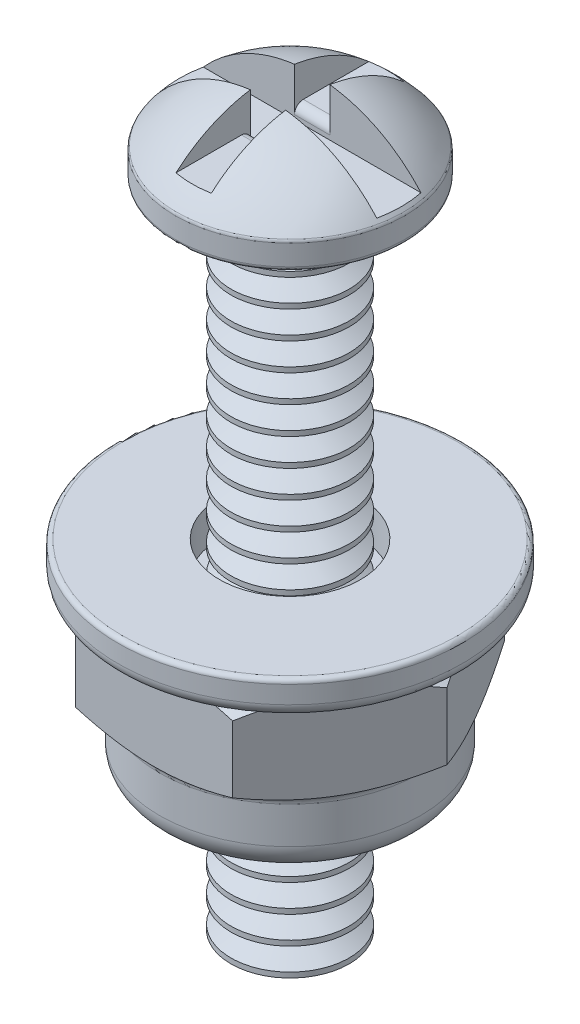
from build123d import *

# Parameters (mm, degrees)
SKETCH2_W                          = 1.27
SKETCH2_H                          = 1.778
LONG_CUT_PHILLIPS_DEPTH            = 4.3020001
LONG_CUT_PHILLIPS_DEPTH_BACK       = 4.3020001
SKETCH3_W                          = 1.016
SKETCH3_H                          = 1.27
SHORT_CUT_PHILLIPS_DEPTH           = 4.3020001
SHORT_CUT_PHILLIPS_DEPTH_BACK      = 4.3020001
PHILLIPS_FILLET_R                  = 0.254
LPATTERN_THREADS_COUNT             = 24
LPATTERN_THREADS_PITCH             = 0.79375
SKETCH5_R                          = 1.35255
NUT_TAP_HOLE_36_DRILL_0_1065_DEPTH = 2.794
SKETCH8_R                          = 3.7592
SKETCH8_R_2                        = 1.35255
LOCK_NUT_EXTRUDE_DEPTH             = 1.9685
SKETCH9_R                          = 1.778
LOCK_NUT_CUT_DEPTH                 = 0.508
LOCK_NUT_FILLET_1_R                = 0.762
LOCK_NUT_FILLET_2_R                = 0.254
SKETCH7_R                          = 4.953
SKETCH7_R_2                        = 2.032
WASHER_DEPTH                       = 1.016
WASHER_FILLET_1_R                  = 0.381
WASHER_FILLET_2_R                  = 0.127


with BuildPart() as part:
    # Sketch1 → Revolve Screw Body (revolve)
    with BuildSketch(Plane.XY):
        with BuildLine():
            Line((0, 2.3495), (0, -19.05))
            Line((0, -19.05), (1.7018, -19.05))
            Line((1.7018, -19.05), (1.7018, 0))
            Line((1.7018, 0), (3.175, 0))
            ThreePointArc((3.175, 0), (3.264802561, 0.037197439), (3.302, 0.127))
            Line((3.302, 0.127), (3.302, 0.717085514))
            ThreePointArc((3.302, 0.717085514), (3.294617332, 0.759755103), (3.273327656, 0.79746382))
            ThreePointArc((3.273327656, 0.79746382), (1.811317907, 1.941836743), (0, 2.3495))
        make_face()
    revolve(axis=Axis((0, 2.3495, 0), (0, -1, 0)))

    # Sketch2 → Long Cut Phillips (cut, two sides)
    with BuildSketch(Plane(origin=(0, 0, 0), x_dir=(0, 0, -1), z_dir=(1, 0, 0))) as long_cut_phillips_sk:
        with Locations((0, 1.778)):
            Rectangle(SKETCH2_W, SKETCH2_H)
    extrude(amount=LONG_CUT_PHILLIPS_DEPTH, mode=Mode.SUBTRACT)
    extrude(long_cut_phillips_sk.sketch, amount=-LONG_CUT_PHILLIPS_DEPTH_BACK, mode=Mode.SUBTRACT)

    # Sketch3 → Short Cut Phillips (cut, two sides)
    with BuildSketch(Plane.XY) as short_cut_phillips_sk:
        with Locations((0, 1.905)):
            Rectangle(SKETCH3_W, SKETCH3_H)
    extrude(amount=SHORT_CUT_PHILLIPS_DEPTH, mode=Mode.SUBTRACT)
    extrude(short_cut_phillips_sk.sketch, amount=-SHORT_CUT_PHILLIPS_DEPTH_BACK, mode=Mode.SUBTRACT)

    # Phillips Fillet
    phillips_fillet_edges = [part.edges().sort_by_distance(p)[0] for p in [
        (0, 1.27, -0.635),
        (0, 1.27, 0.635),
    ]]
    fillet(phillips_fillet_edges, radius=PHILLIPS_FILLET_R)

    # Sketch4 → Cut Threading (revolve, cut)
    with BuildSketch(Plane.XY):
        Polygon((2.624157664, -18.653125), (2.624157664, -19.446875), (1.830407664, -19.446875), (1.143, -19.05), (1.830407664, -18.653125), align=None)
    cut_threading = revolve(axis=Axis((0, -19.05, 0), (0, 1, 0)), mode=Mode.SUBTRACT)

    # LPattern Threads: Cut Threading ×24
    with Locations(*[(0, i * LPATTERN_THREADS_PITCH, 0) for i in range(1, LPATTERN_THREADS_COUNT)]):
        add(cut_threading, mode=Mode.SUBTRACT)


with BuildPart() as body_2:
    # Sketch5 → Nut Tap Hole #36 Drill 0.1065 (new body)
    with BuildSketch(Plane(origin=(0, -10.000000066, 0), x_dir=(-1, 0, 0), z_dir=(0, -1, 0))):
        Polygon((-4.516726626, 0), (-2.258363313, -3.9116), (2.258363313, -3.9116), (4.516726626, 0), (2.258363313, 3.9116), (-2.258363313, 3.9116), align=None)
        Circle(SKETCH5_R, mode=Mode.SUBTRACT)
    extrude(amount=NUT_TAP_HOLE_36_DRILL_0_1065_DEPTH)

    # Sketch6 → Nut Angle Edges (revolve, cut)
    with BuildSketch(Plane.XY):
        Polygon((3.7592, -10.000000066), (4.516726626, -10.000000066), (4.516726626, -10.437358267), align=None)
        Polygon((3.7592, -12.794000066), (4.516726626, -12.794000066), (4.516726626, -12.356641865), align=None)
    revolve(axis=Axis((0, -10.000000066, 0), (0, -1, 0)), mode=Mode.SUBTRACT)

    # Sketch8 → Lock Nut Extrude (add)
    with BuildSketch(Plane.XZ.offset(12.794000066)):
        Circle(SKETCH8_R)
        Circle(SKETCH8_R_2, mode=Mode.SUBTRACT)
    extrude(amount=LOCK_NUT_EXTRUDE_DEPTH)

    # Sketch9 → Lock Nut Cut (cut)
    with BuildSketch(Plane.XZ.offset(14.762500066)):
        Circle(SKETCH9_R)
    extrude(amount=-LOCK_NUT_CUT_DEPTH, mode=Mode.SUBTRACT)

    # Lock Nut Fillet-1
    lock_nut_fillet_1_edges = [body_2.edges().sort_by_distance(p)[0] for p in [
        (-3.7592, -14.762500066, 0),
    ]]
    fillet(lock_nut_fillet_1_edges, radius=LOCK_NUT_FILLET_1_R)

    # Lock Nut Fillet-2
    lock_nut_fillet_2_edges = [body_2.edges().sort_by_distance(p)[0] for p in [
        (-3.7592, -12.794000066, 0),
        (-1.778, -14.762500066, 0),
    ]]
    fillet(lock_nut_fillet_2_edges, radius=LOCK_NUT_FILLET_2_R)


with BuildPart() as body_3:
    # Sketch7 → Washer (new body)
    with BuildSketch(Plane.XZ.offset(10.000000066)):
        Circle(SKETCH7_R)
        Circle(SKETCH7_R_2, mode=Mode.SUBTRACT)
    extrude(amount=-WASHER_DEPTH)

    # Washer Fillet-1
    washer_fillet_1_edges = [body_3.edges().sort_by_distance(p)[0] for p in [
        (-4.953, -10.000000066, 0),
    ]]
    fillet(washer_fillet_1_edges, radius=WASHER_FILLET_1_R)

    # Washer Fillet-2
    washer_fillet_2_edges = [body_3.edges().sort_by_distance(p)[0] for p in [
        (-4.953, -8.984000066, 0),
    ]]
    fillet(washer_fillet_2_edges, radius=WASHER_FILLET_2_R)


solid = Compound([part.part, body_2.part, body_3.part])
